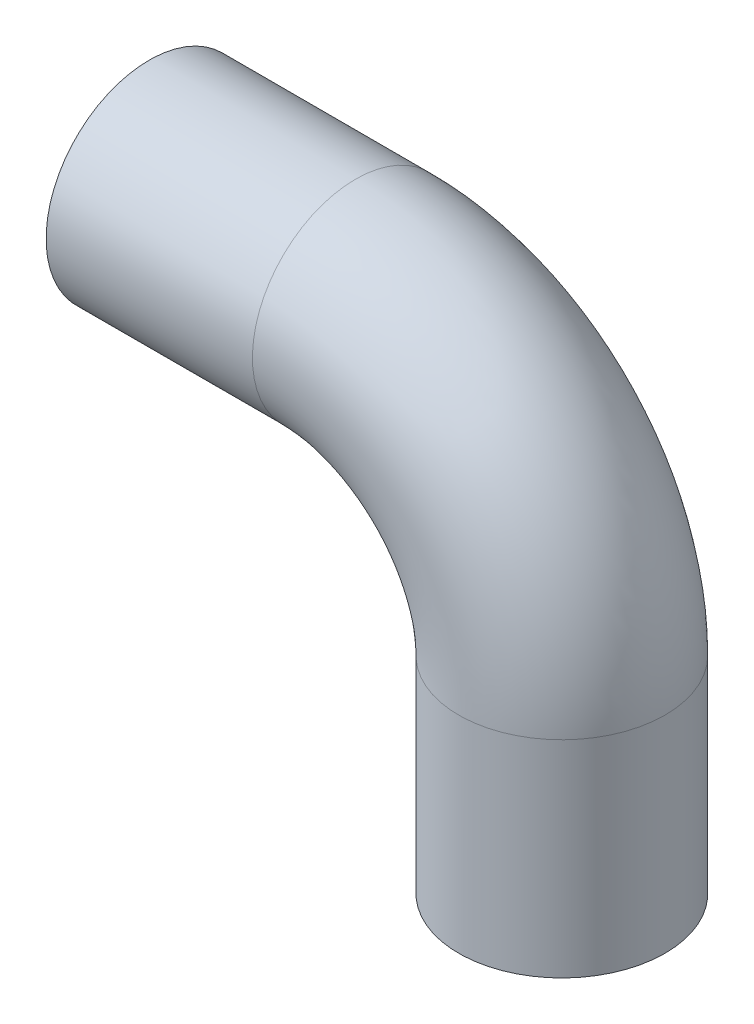
from build123d import *

# Parameters (mm, degrees)
SKETCH_48_R = 5


with BuildPart() as part:
    # 扫描7: sweep along a path in 草图2
    with BuildLine(Plane.XY) as sweep_7_path:
        Line((0, 0), (10, 0))
        ThreePointArc((10, 0), (17.071067812, -2.928932188), (20, -10))
        Line((20, -10), (20, -20))
    # 草图48 → 扫描7 (sweep)
    with BuildSketch(Plane(origin=(0, 0, 0), x_dir=(0, 0, -1), z_dir=(1, 0, 0))):
        Circle(SKETCH_48_R)
    sweep(path=sweep_7_path.line)


solid = part.part
